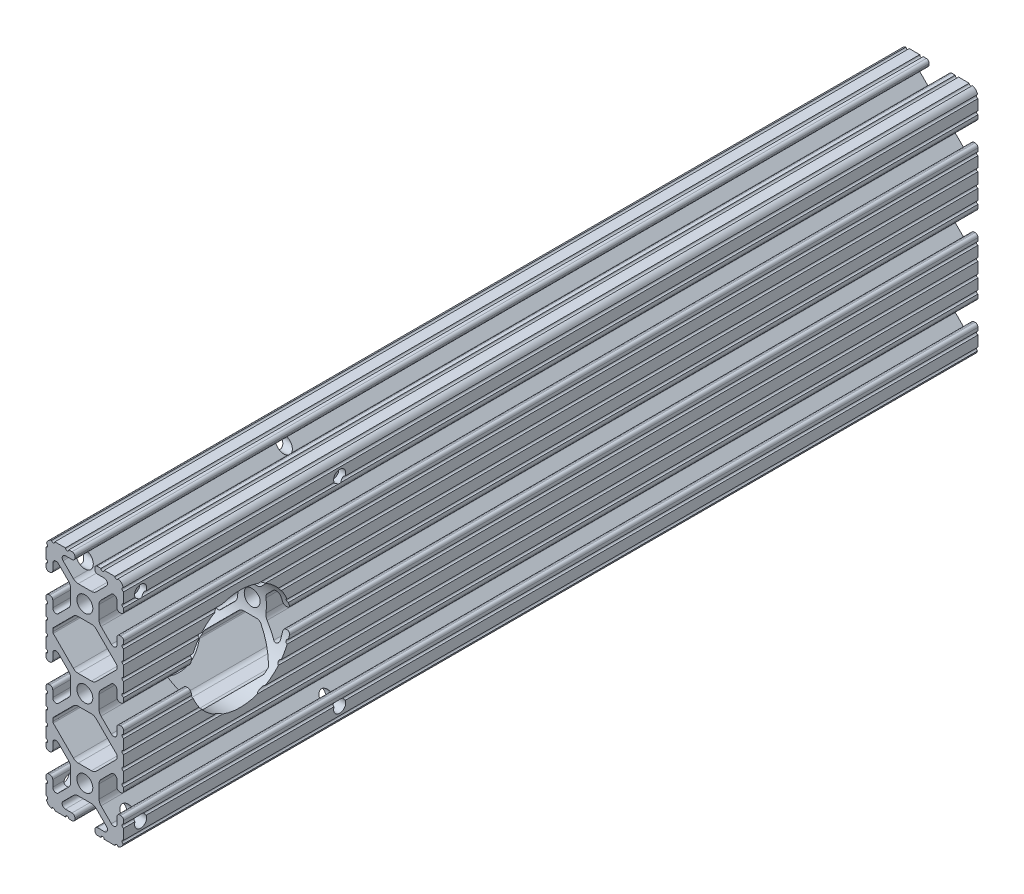
from build123d import *

# Parameters (mm, degrees)
BOSS_EXTRUDE1_DEPTH     = 139.7
SKETCH5_R               = 0.55245
CUT_EXTRUDE1_DEPTH      = 146.358143907
CUT_EXTRUDE1_DEPTH_BACK = 146.358143907
BOSS_EXTRUDE2_DEPTH     = 139.7
CUT_EXTRUDE2_DEPTH      = 146.358143907
CUT_EXTRUDE2_DEPTH_BACK = 146.358143907
SKETCH8_R               = 1.9812
SKETCH8_R_2             = 16.637
CUT_EXTRUDE3_DEPTH      = 148.013128665


with BuildPart() as part:
    # Sketch4 → Boss-Extrude1 (new, symmetric)
    with BuildSketch(Plane.XY):
        with BuildLine():
            Line((4.190365, -38.1), (10.11729625, -38.1))
            ThreePointArc((10.11729625, -38.1), (11.943543585, -37.343543585), (12.7, -35.51729625))
            Line((12.7, -35.51729625), (12.7, -29.590365))
            ThreePointArc((12.7, -29.590365), (12.42492494, -28.92627506), (11.760835, -28.6512))
            Line((11.760835, -28.6512), (11.429365, -28.6512))
            ThreePointArc((11.429365, -28.6512), (10.76527506, -28.92627506), (10.4902, -29.590365))
            Line((10.4902, -29.590365), (10.4902, -31.748478019))
            ThreePointArc((10.4902, -31.748478019), (9.830707141, -32.735478831), (8.666460301, -32.503895736))
            Line((8.666460301, -32.503895736), (5.299899128, -29.137334563))
            ThreePointArc((5.299899128, -29.137334563), (4.817571085, -28.415479634), (4.6482, -27.56399369))
            Line((4.6482, -27.56399369), (4.6482, -25.4))
            Line((4.6482, -25.4), (2.6035, -25.4))
            ThreePointArc((2.6035, -25.4), (1.840952505, -27.240952505), (0, -28.0035))
            Line((0, -28.0035), (0, -30.0482))
            Line((0, -30.0482), (2.16399369, -30.0482))
            ThreePointArc((2.16399369, -30.0482), (3.015479634, -30.217571085), (3.737334563, -30.699899128))
            Line((3.737334563, -30.699899128), (7.103895736, -34.066460301))
            ThreePointArc((7.103895736, -34.066460301), (7.335478831, -35.230707141), (6.348478019, -35.8902))
            Line((6.348478019, -35.8902), (4.190365, -35.8902))
            ThreePointArc((4.190365, -35.8902), (3.52627506, -36.16527506), (3.2512, -36.829365))
            Line((3.2512, -36.829365), (3.2512, -37.160835))
            ThreePointArc((3.2512, -37.160835), (3.52627506, -37.82492494), (4.190365, -38.1))
        make_face()
    extrude(amount=BOSS_EXTRUDE1_DEPTH, both=True)

    # Sketch5 → Cut-Extrude1 (cut, two sides)
    with BuildSketch(Plane.XY) as cut_extrude1_sk:
        with Locations((10.356153152, -38.1)):
            Circle(SKETCH5_R)
        with Locations((5.796028019, -38.1)):
            Circle(SKETCH5_R)
        with Locations((12.7, -35.756153152)):
            Circle(SKETCH5_R)
        with Locations((12.7, -31.196028019)):
            Circle(SKETCH5_R)
    extrude(amount=CUT_EXTRUDE1_DEPTH, mode=Mode.SUBTRACT)
    extrude(cut_extrude1_sk.sketch, amount=-CUT_EXTRUDE1_DEPTH_BACK, mode=Mode.SUBTRACT)

    # Mirror1: part across plane


with BuildPart() as part_1:
    add(part.part)
    add(part.part.mirror(Plane(origin=(4.6482, -25.4, 139.7), x_dir=(0, 0, 1), z_dir=(0, -1, 0))))

    # Sketch6 → Boss-Extrude2 (add, symmetric)
    with BuildSketch(Plane.XY):
        with BuildLine():
            Line((12.7, -14.491396848), (12.7, -12.7))
            Line((12.7, -12.7), (9.803703152, -12.7))
            Line((9.803703152, -12.7), (9.803703152, -15.596296848))
            Line((9.803703152, -15.596296848), (12.7, -15.596296848))
            ThreePointArc((12.7, -15.596296848), (12.14755, -15.043846848), (12.7, -14.491396848))
        make_face()
    extrude(amount=BOSS_EXTRUDE2_DEPTH, both=True)

    # Sketch7 → Cut-Extrude2 (cut, two sides)
    with BuildSketch(Plane.XY) as cut_extrude2_sk:
        with BuildLine():
            Line((5.420615149, -18.416820286), (10.328391141, -13.509044294))
            ThreePointArc((10.328391141, -13.509044294), (10.448147248, -13.329816615), (10.4902, -13.118403152))
            Line((10.4902, -13.118403152), (10.4902, -12.7))
            Line((10.4902, -12.7), (0, -12.7))
            Line((0, -12.7), (5.420615149, -18.416820286))
        make_face()
    extrude(amount=CUT_EXTRUDE2_DEPTH, mode=Mode.SUBTRACT)
    extrude(cut_extrude2_sk.sketch, amount=-CUT_EXTRUDE2_DEPTH_BACK, mode=Mode.SUBTRACT)

    # Mirror2: part across plane


with BuildPart() as part_2:
    add(part_1.part)
    add(part_1.part.mirror(Plane(origin=(4.190365, -12.7, 139.7), x_dir=(0, 0, 1), z_dir=(0, -1, 0))))

    # SurfaceCut1
    split(bisect_by=Plane(origin=(0, 0, 0), x_dir=(1, 0, 0), z_dir=(0, 1, 0)), keep=Keep.BOTTOM)

    # Mirror3: part across plane


with BuildPart() as part_3:
    add(part_2.part)
    add(part_2.part.mirror(Plane(origin=(0, 0, 0), x_dir=(0, 0, 1), z_dir=(1, 0, 0))))

    # Mirror4: part across plane


with BuildPart() as part_4:
    add(part_3.part)
    add(part_3.part.mirror(Plane.ZX))

    # Sketch8 → Cut-Extrude3 (cut, through all)
    with BuildSketch(Plane.ZY.offset(12.7)):
        with Locations(Location((134.1501, 32.5501, 0), (0, 0, 336.13303643))):
            Circle(SKETCH8_R)
        with Locations(Location((69.0499, 32.5501, 0), (0, 0, 336.13303643))):
            Circle(SKETCH8_R)
        with Locations(Location((69.0499, -32.5501, 0), (0, 0, 23.86696357))):
            Circle(SKETCH8_R)
        with Locations(Location((134.1501, -32.5501, 0), (0, 0, 23.86696357))):
            Circle(SKETCH8_R)
        with Locations(Location((101.6, 0, 0), (0, 0, 7.473703708))):
            Circle(SKETCH8_R_2)
    extrude(amount=-CUT_EXTRUDE3_DEPTH, mode=Mode.SUBTRACT)


solid = part_4.part
